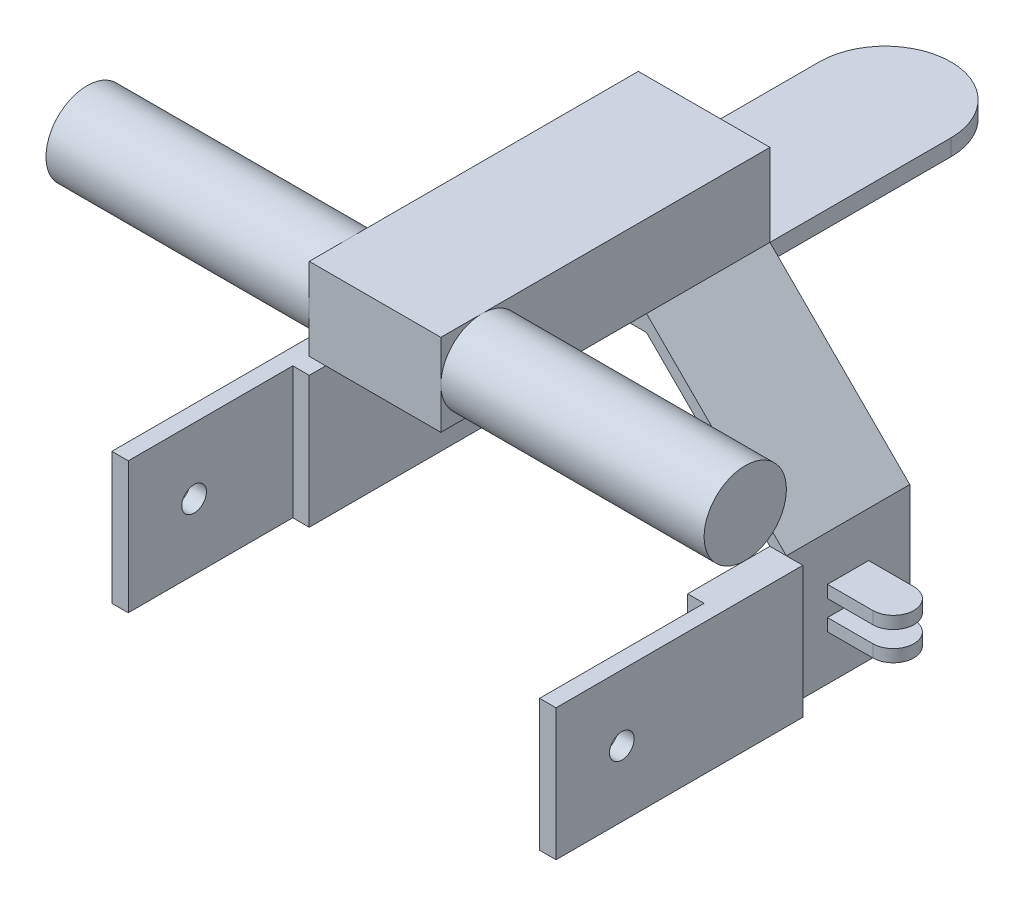
from build123d import *

# Parameters (mm, degrees)
EXTRUDE_1_DEPTH     = 30
SKETCH_2_W          = 32
SKETCH_2_H          = 4
EXTRUDE_2_DEPTH     = 60
CUT_EXTRUDE_1_DEPTH = 30
SKETCH_6_W          = 4
SKETCH_6_H          = 32
EXTRUDE_4_DEPTH     = 20
SKETCH_7_W          = 4
SKETCH_7_H          = 60
EXTRUDE_5_DEPTH     = 32
SKETCH_8_R          = 3
CUT_EXTRUDE_3_DEPTH = 109
SKETCH_9_W          = 32
SKETCH_9_H          = 80
EXTRUDE_6_DEPTH     = 20
SKETCH_10_R         = 10
EXTRUDE_7_DEPTH     = 80
SKETCH_11_W         = 10
SKETCH_11_H         = 3
EXTRUDE_8_DEPTH     = 16
CUT_EXTRUDE_4_DEPTH = 16


with BuildPart() as part:
    # 草图1 → 凸台-拉伸1 (new body)
    with BuildSketch(Plane.XY):
        Polygon((-50, 16), (-16, 50), (16, 50), (50, 16), (50, -16), (46, -16), (46, 16), (16, 46), (-16, 46), (-46, 16), (-46, -16), (-50, -16), align=None)
    extrude(amount=EXTRUDE_1_DEPTH)

    # 草图2 → 凸台-拉伸2 (add)
    with BuildSketch(Plane(origin=(0, 0, 0), x_dir=(-1, 0, 0), z_dir=(0, 0, -1))):
        with Locations((0, 48)):
            Rectangle(SKETCH_2_W, SKETCH_2_H)
    extrude(amount=EXTRUDE_2_DEPTH)

    # 草图3 → 切除-拉伸1 (cut)
    with BuildSketch(Plane(origin=(0, 50, 0), x_dir=(1, 0, 0), z_dir=(0, 1, 0))):
        with BuildLine():
            Line((-16, 44), (-16, 67.226604698))
            Line((-16, 67.226604698), (16, 67.226604698))
            Line((16, 67.226604698), (16, 44))
            ThreePointArc((16, 44), (0, 60), (-16, 44))
        make_face()
    extrude(amount=-CUT_EXTRUDE_1_DEPTH, mode=Mode.SUBTRACT)

    # 草图6 → 凸台-拉伸4 (add)
    with BuildSketch(Plane.XY.offset(30)):
        with Locations((-48, 0)):
            Rectangle(SKETCH_6_W, SKETCH_6_H)
        with Locations((48, 0)):
            Rectangle(SKETCH_6_W, SKETCH_6_H)
    extrude(amount=EXTRUDE_4_DEPTH)

    # 草图7 → 凸台-拉伸5 (add)
    with BuildSketch(Plane(origin=(0, 16, 0), x_dir=(1, 0, 0), z_dir=(0, 1, 0))):
        with Locations((-52, -60)):
            Rectangle(SKETCH_7_W, SKETCH_7_H)
        with Locations((52, -60)):
            Rectangle(SKETCH_7_W, SKETCH_7_H)
    extrude(amount=-EXTRUDE_5_DEPTH)

    # 草图8 → 切除-拉伸3 (cut, through all)
    with BuildSketch(Plane.ZY.offset(54)):
        with Locations((74, 0)):
            Circle(SKETCH_8_R)
    extrude(amount=-CUT_EXTRUDE_3_DEPTH, mode=Mode.SUBTRACT)

    # 草图9 → 凸台-拉伸6 (add)
    with BuildSketch(Plane(origin=(0, 50, 0), x_dir=(1, 0, 0), z_dir=(0, 1, 0))):
        with Locations((0, -40)):
            Rectangle(SKETCH_9_W, SKETCH_9_H)
    extrude(amount=EXTRUDE_6_DEPTH)

    # 草图10 → 凸台-拉伸7 (add, symmetric)
    with BuildSketch(Plane(origin=(0, 0, 0), x_dir=(0, 0, -1), z_dir=(1, 0, 0))):
        with Locations((-70, 60)):
            Circle(SKETCH_10_R)
    extrude(amount=EXTRUDE_7_DEPTH, both=True)

    # 草图11 → 凸台-拉伸8 (add)
    with BuildSketch(Plane(origin=(50, 0, 0), x_dir=(0, 0, -1), z_dir=(1, 0, 0))):
        with Locations((-15, -3.5)):
            Rectangle(SKETCH_11_W, SKETCH_11_H)
        with Locations((-15, 3.5)):
            Rectangle(SKETCH_11_W, SKETCH_11_H)
    extrude(amount=EXTRUDE_8_DEPTH)

    # 草图12 → 切除-拉伸4 (cut)
    with BuildSketch(Plane(origin=(0, 5, 0), x_dir=(1, 0, 0), z_dir=(0, 1, 0))):
        with BuildLine():
            Line((61, -10), (68.714035349, -10))
            Line((68.714035349, -10), (68.714035349, -20))
            Line((68.714035349, -20), (61, -20))
            ThreePointArc((61, -20), (66, -15), (61, -10))
        make_face()
    extrude(amount=-CUT_EXTRUDE_4_DEPTH, mode=Mode.SUBTRACT)


solid = part.part
